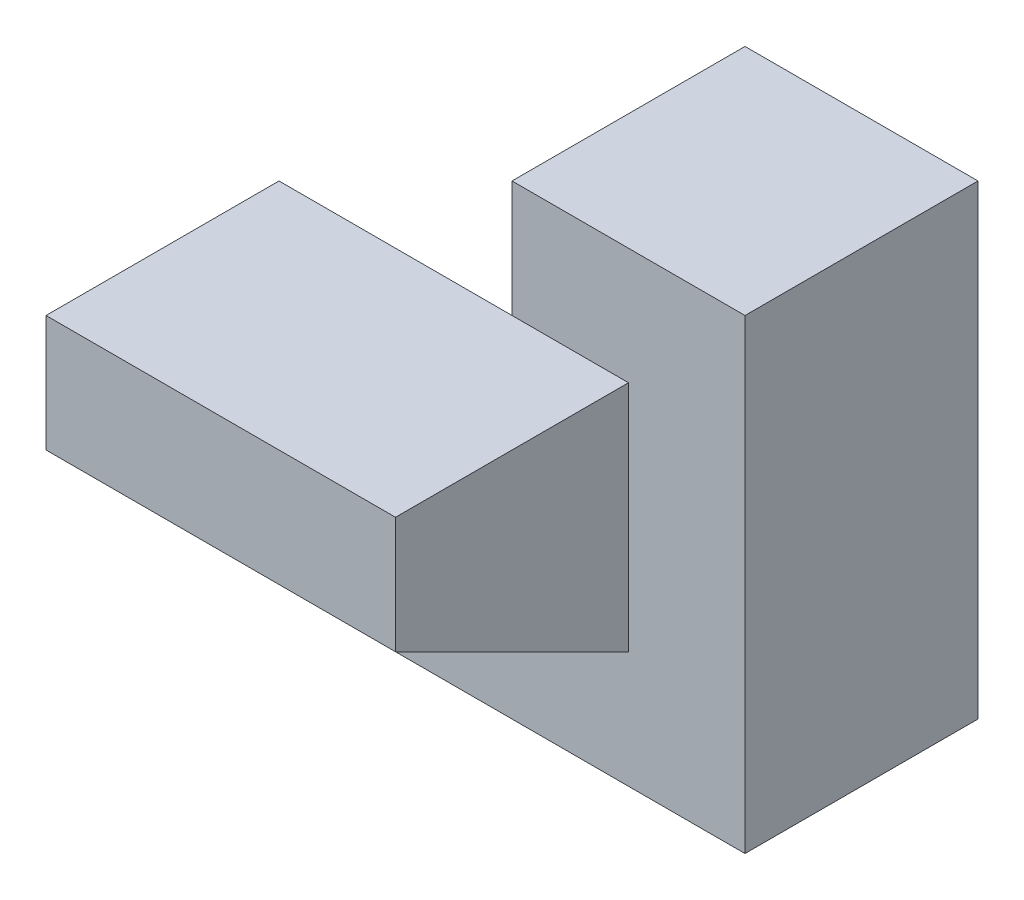
from build123d import *

# Parameters (mm, degrees)
SKETCH1_W                = 2
SKETCH1_H                = 4
BOSS_EXTRUDE1_DEPTH      = 2
BOSS_EXTRUDE2_DEPTH      = 2
BOSS_EXTRUDE2_DEPTH_BACK = 1


with BuildPart() as part:
    # Sketch1 → Boss-Extrude1 (new body)
    with BuildSketch(Plane(origin=(0, 0, 0), x_dir=(0, 0, -1), z_dir=(1, 0, 0))):
        with Locations((1, 2)):
            Rectangle(SKETCH1_W, SKETCH1_H)
    extrude(amount=BOSS_EXTRUDE1_DEPTH)

    # Sketch2 → Boss-Extrude2 (add, two sides)
    with BuildSketch(Plane.ZY) as boss_extrude2_sk:
        Polygon((-2, 0), (0, 3), (2, 3), (2, 2), (0, 1), (0, 0), align=None)
    extrude(amount=BOSS_EXTRUDE2_DEPTH)
    extrude(boss_extrude2_sk.sketch, amount=-BOSS_EXTRUDE2_DEPTH_BACK)


solid = part.part
